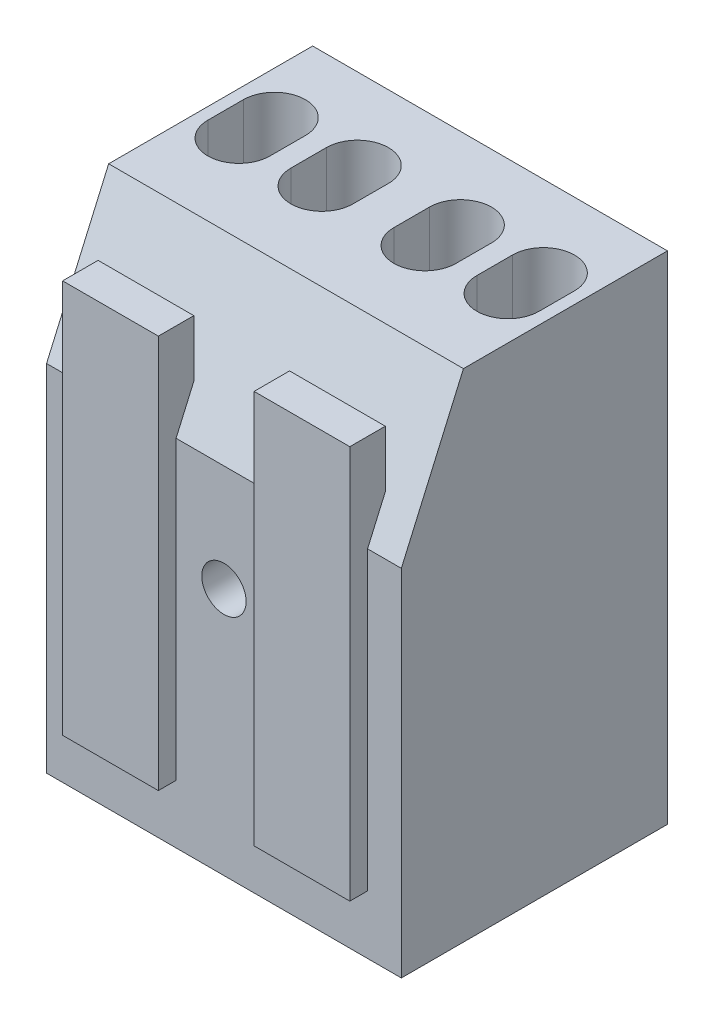
from build123d import *

# Parameters (mm, degrees)
SKETCH1_W           = 20
SKETCH1_H           = 28
BOSS_EXTRUDE1_DEPTH = 15
CUT_EXTRUDE1_DEPTH  = 21
CUT_EXTRUDE2_DEPTH  = 5
SKETCH4_W           = 5.397016415
SKETCH4_H           = 22.187734152
BOSS_EXTRUDE2_DEPTH = 1
SKETCH5_R           = 1.25
CUT_EXTRUDE3_DEPTH  = 16


with BuildPart() as part:
    # Sketch1 → Boss-Extrude1 (new body)
    with BuildSketch(Plane.XY):
        Rectangle(SKETCH1_W, SKETCH1_H)
    extrude(amount=BOSS_EXTRUDE1_DEPTH)

    # Sketch2 → Cut-Extrude1 (cut, through all)
    with BuildSketch(Plane(origin=(10, 0, 0), x_dir=(0, 0, -1), z_dir=(1, 0, 0))):
        Polygon((-11.5, 14), (-15, 14), (-15, 6), align=None)
    extrude(amount=-CUT_EXTRUDE1_DEPTH, mode=Mode.SUBTRACT)

    # Sketch3 → Cut-Extrude2 (cut)
    with BuildSketch(Plane(origin=(0, 14, 0), x_dir=(1, 0, 0), z_dir=(0, 1, 0))):
        with BuildLine():
            Line((4.654488589, -4.572843843), (4.654488589, -6.572843843))
            ThreePointArc((4.654488589, -6.572843843), (2.904488589, -8.322843843), (1.154488589, -6.572843843))
            Line((1.154488589, -6.572843843), (1.154488589, -4.572843843))
            ThreePointArc((1.154488589, -4.572843843), (2.904488589, -2.822843843), (4.654488589, -4.572843843))
        make_face()
        with BuildLine():
            Line((9.333625698, -4.572843843), (9.333625698, -6.572843843))
            ThreePointArc((9.333625698, -6.572843843), (7.583625698, -8.322843843), (5.833625698, -6.572843843))
            Line((5.833625698, -6.572843843), (5.833625698, -4.572843843))
            ThreePointArc((5.833625698, -4.572843843), (7.583625698, -2.822843843), (9.333625698, -4.572843843))
        make_face()
    cut_extrude2 = extrude(amount=-CUT_EXTRUDE2_DEPTH, mode=Mode.SUBTRACT)

    # Sketch4 → Boss-Extrude2 (add, symmetric)
    with BuildSketch(Plane.XY.offset(15)):
        with Locations((5.397016416, 0.393532447)):
            Rectangle(SKETCH4_W, SKETCH4_H)
    boss_extrude2 = extrude(amount=BOSS_EXTRUDE2_DEPTH, both=True)

    # Mirror1: Cut-Extrude2, Boss-Extrude2 across plane
    add(cut_extrude2.mirror(Plane(origin=(0, 0, 0), x_dir=(0, 0, 1), z_dir=(1, 0, 0))), mode=Mode.SUBTRACT)
    add(boss_extrude2.mirror(Plane(origin=(0, 0, 0), x_dir=(0, 0, 1), z_dir=(1, 0, 0))))

    # Sketch5 → Cut-Extrude3 (cut, through all)
    with BuildSketch(Plane.XY.offset(15)):
        Circle(SKETCH5_R)
    extrude(amount=-CUT_EXTRUDE3_DEPTH, mode=Mode.SUBTRACT)


solid = part.part
